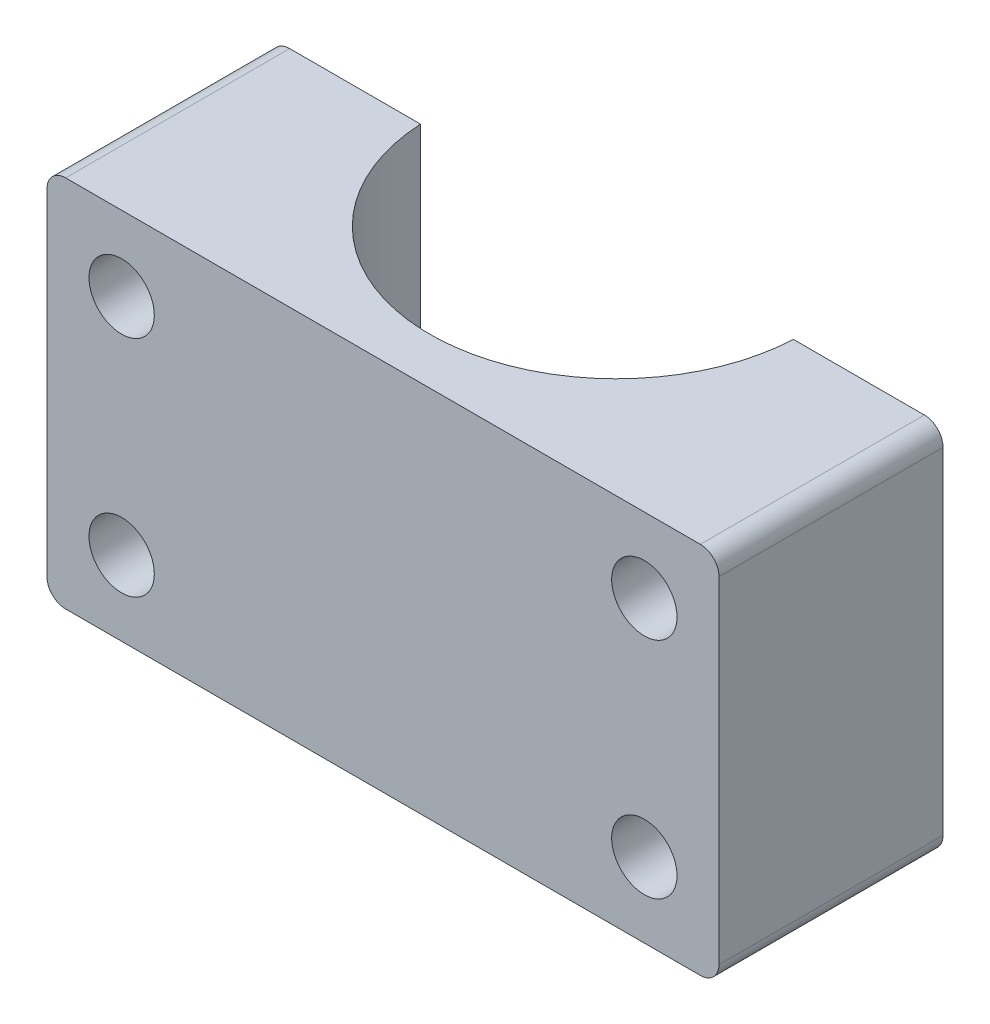
from build123d import *

# Parameters (mm, degrees)
BOSS_EXTRUDE1_DEPTH = 20
SKETCH2_R           = 1.75
CUT_EXTRUDE1_DEPTH  = 13
FILLET1_R           = 1


with BuildPart() as part:
    # Sketch1 → Boss-Extrude1 (new body)
    with BuildSketch(Plane(origin=(0, 0, 0), x_dir=(1, 0, 0), z_dir=(0, 1, 0))):
        with BuildLine():
            Line((-18, 0), (-18, -12))
            Line((-18, -12), (18, -12))
            Line((18, -12), (18, 0))
            Line((18, 0), (9.987492178, 0))
            ThreePointArc((9.987492178, 0), (0, -9.5), (-9.987492178, 0))
            Line((-9.987492178, 0), (-18, 0))
        make_face()
    extrude(amount=BOSS_EXTRUDE1_DEPTH)

    # Sketch2 → Cut-Extrude1 (cut, through all)
    with BuildSketch(Plane.XY.offset(12)):
        with Locations((-14, 16)):
            Circle(SKETCH2_R)
        with Locations((-14, 4)):
            Circle(SKETCH2_R)
        with Locations((14, 4)):
            Circle(SKETCH2_R)
        with Locations((14, 16)):
            Circle(SKETCH2_R)
    extrude(amount=-CUT_EXTRUDE1_DEPTH, mode=Mode.SUBTRACT)

    # Fillet1
    fillet1_edges = [part.edges().sort_by_distance(p)[0] for p in [
        (-18, 20, 6),
        (-18, 0, 6),
        (18, 0, 6),
        (18, 20, 6),
    ]]
    fillet(fillet1_edges, radius=FILLET1_R)


solid = part.part
